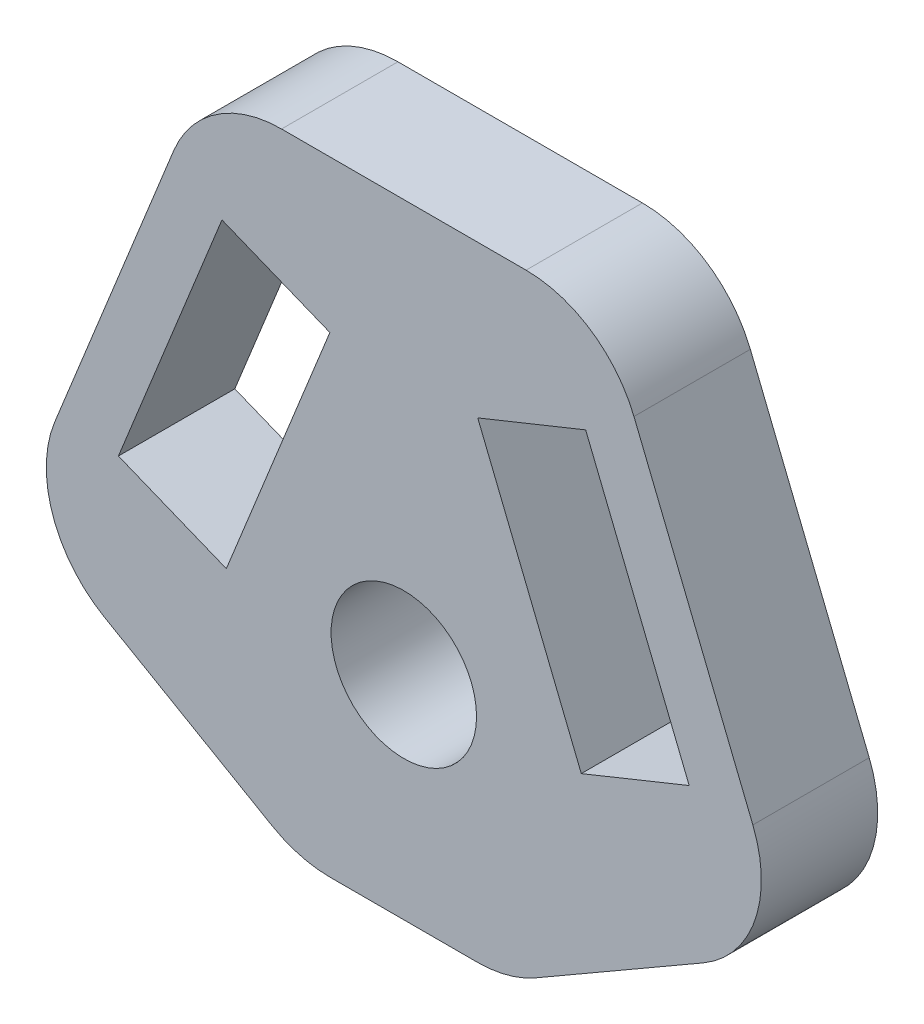
from build123d import *

# Parameters (mm, degrees)
SKETCH_1_R      = 2.5
EXTRUDE_1_DEPTH = 4
FILLET_1_R      = 4


with BuildPart() as part:
    # ｽｹｯﾁ1 → ﾎﾞｽ - 押し出し1 (new body)
    with BuildSketch(Plane.XY):
        Polygon((-6.9, 14.13928001), (6.9, 14.13928001), (13.299484522, -1.7), (3.6, -7.3), (-3.6, -7.3), (-13.299484522, -1.7), align=None)
        Circle(SKETCH_1_R, mode=Mode.SUBTRACT)
        Polygon((2.541237363, 8.910793136), (6.249972781, 10.409219509), (9.808735418, 1.600972891), (6.1, 0.102546517), align=None, mode=Mode.SUBTRACT)
        Polygon((-6.1, 0.102546517), (-2.541237363, 8.910793136), (-6.249972781, 10.409219509), (-9.808735418, 1.600972891), align=None, mode=Mode.SUBTRACT)
    extrude(amount=EXTRUDE_1_DEPTH)

    # ﾌｨﾚｯﾄ1
    fillet_1_edges = [part.edges().sort_by_distance(p)[0] for p in [
        (13.299484522, -1.7, 2),
        (3.6, -7.3, 2),
        (-3.6, -7.3, 2),
        (-13.299484522, -1.7, 2),
        (-6.9, 14.13928001, 2),
        (6.9, 14.13928001, 2),
    ]]
    fillet(fillet_1_edges, radius=FILLET_1_R)


solid = part.part
